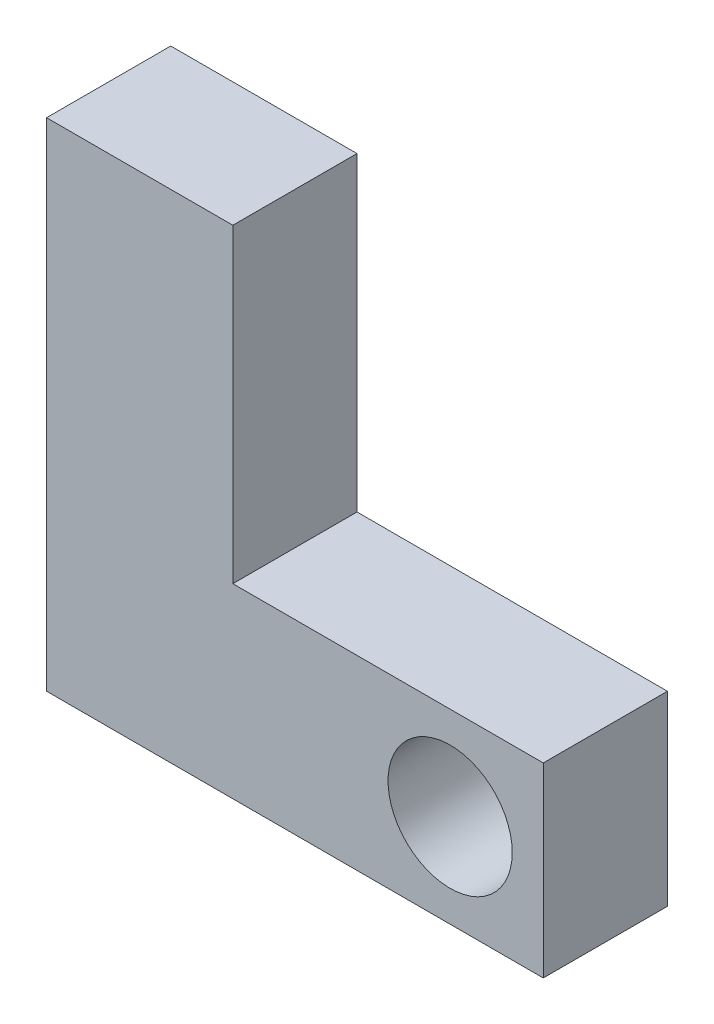
from build123d import *

# Parameters (mm, degrees)
EXTRUDE1_DEPTH     = 6.35
SKETCH2_R          = 3.175
CUT_EXTRUDE1_DEPTH = 7.35
SKETCH3_R          = 1.609646759
CUT_EXTRUDE2_DEPTH = 6.35


with BuildPart() as part:
    # Sketch1 → Extrude1 (new body)
    with BuildSketch(Plane.XY):
        Polygon((-19.501167272, 6.290815989), (-9.976167272, 6.290815989), (-9.976167272, -9.584184011), (5.898832728, -9.584184011), (5.898832728, -19.109184011), (-19.501167272, -19.109184011), align=None)
    extrude(amount=EXTRUDE1_DEPTH)

    # Sketch2 → Cut-Extrude1 (cut, through all)
    with BuildSketch(Plane.XY.offset(6.35)):
        with Locations((1.136332728, -14.346684011)):
            Circle(SKETCH2_R)
    extrude(amount=-CUT_EXTRUDE1_DEPTH, mode=Mode.SUBTRACT)

    # Sketch3 → Cut-Extrude2 (cut)
    with BuildSketch(Plane.ZY.offset(19.501167272)):
        with Locations((3.175, -6.409184011)):
            Circle(SKETCH3_R)
    extrude(amount=-CUT_EXTRUDE2_DEPTH, mode=Mode.SUBTRACT)


solid = part.part
